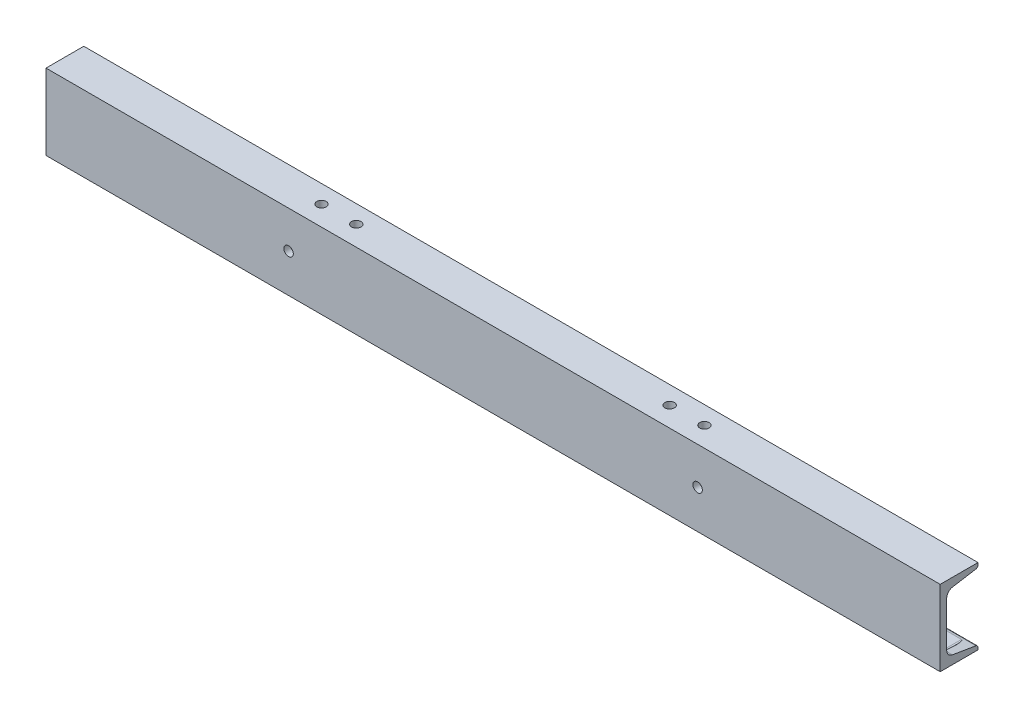
from build123d import *

# Parameters (mm, degrees)
STRUCTURAL_MEMBER1_DEPTH = 900
SKETCH12_R               = 4.7625
CUT_EXTRUDE1_DEPTH       = 454.210052427
CUT_EXTRUDE2_DEPTH       = 40
SKETCH16_R               = 4.7625
CUT_EXTRUDE3_DEPTH       = 454.210052526
SKETCH17_R               = 4.7625
CUT_EXTRUDE4_DEPTH       = 454.210052526


with BuildPart() as part:
    # Sketch11 → Structural Member1 (new body)
    with BuildSketch(Plane(origin=(-450, 0, 0), x_dir=(0, 0, -1), z_dir=(1, 0, 0))):
        with BuildLine():
            Line((0, -38.1), (0, 38.1))
            Line((0, 38.1), (38.0492, 38.1))
            Line((38.0492, 38.1), (38.0492, 35.942335136))
            ThreePointArc((38.0492, 35.942335136), (37.447280466, 34.300554363), (35.926803066, 33.436899509))
            Line((35.926803066, 33.436899509), (12.283671721, 29.496090157))
            ThreePointArc((12.283671721, 29.496090157), (8.178382741, 27.164222052), (6.5532, 22.731413966))
            Line((6.5532, 22.731413966), (6.5532, -22.731413966))
            ThreePointArc((6.5532, -22.731413966), (8.178382741, -27.164222052), (12.283671721, -29.496090157))
            Line((12.283671721, -29.496090157), (35.926803066, -33.436899509))
            ThreePointArc((35.926803066, -33.436899509), (37.447280466, -34.300554363), (38.0492, -35.942335136))
            Line((38.0492, -35.942335136), (38.0492, -38.1))
            Line((38.0492, -38.1), (0, -38.1))
        make_face()
    extrude(amount=STRUCTURAL_MEMBER1_DEPTH)

    # Sketch12 → Cut-Extrude1 (cut, through all)
    with BuildSketch(Plane(origin=(0, 0, 0), x_dir=(1, 0, 0), z_dir=(0, 1, 0))):
        with Locations(Location((-425, 20, 0), (0, 0, 270))):
            Circle(SKETCH12_R)
        with Locations(Location((425, 20, 0), (0, 0, 270))):
            Circle(SKETCH12_R)
    extrude(amount=-CUT_EXTRUDE1_DEPTH, mode=Mode.SUBTRACT)

    # Sketch15 → Cut-Extrude2 (cut)
    with BuildSketch(Plane(origin=(0, 0, -6.5532), x_dir=(-1, 0, 0), z_dir=(0, 0, -1))):
        with BuildLine():
            Line((-412.5, -33.1), (-437.5, -33.1))
            ThreePointArc((-437.5, -33.1), (-442.5, -28.1), (-437.5, -23.1))
            Line((-437.5, -23.1), (-412.5, -23.1))
            ThreePointArc((-412.5, -23.1), (-407.5, -28.1), (-412.5, -33.1))
        make_face()
        with BuildLine():
            Line((412.5, -33.1), (437.5, -33.1))
            ThreePointArc((437.5, -33.1), (442.5, -28.1), (437.5, -23.1))
            Line((437.5, -23.1), (412.5, -23.1))
            ThreePointArc((412.5, -23.1), (407.5, -28.1), (412.5, -33.1))
        make_face()
    extrude(amount=CUT_EXTRUDE2_DEPTH, mode=Mode.SUBTRACT)

    # Sketch16 → Cut-Extrude3 (cut, through all)
    with BuildSketch(Plane(origin=(0, 0, 0), x_dir=(1, 0, 0), z_dir=(0, 1, 0))):
        with Locations(Location((-192.7, 20, 0), (0, 0, 270))):
            Circle(SKETCH16_R)
        with Locations(Location((-157.7, 20, 0), (0, 0, 270))):
            Circle(SKETCH16_R)
        with Locations(Location((157.7, 20, 0), (0, 0, 90))):
            Circle(SKETCH16_R)
        with Locations(Location((192.7, 20, 0), (0, 0, 90))):
            Circle(SKETCH16_R)
    extrude(amount=CUT_EXTRUDE3_DEPTH, mode=Mode.SUBTRACT)

    # Sketch17 → Cut-Extrude4 (cut, through all)
    with BuildSketch(Plane.XY):
        with Locations((205.8375, 0.6)):
            Circle(SKETCH17_R)
        with Locations((-205.8375, 0.6)):
            Circle(SKETCH17_R)
    extrude(amount=-CUT_EXTRUDE4_DEPTH, mode=Mode.SUBTRACT)


solid = part.part
